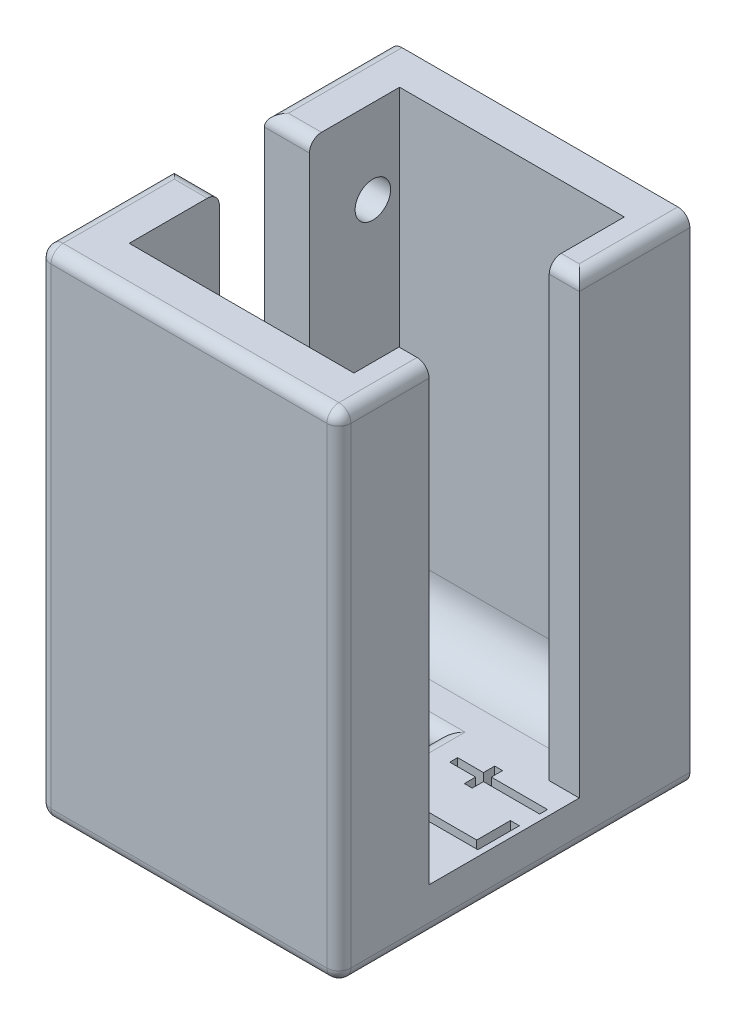
from build123d import *

# Parameters (mm, degrees)
BOSS_EXTRUDE2_DEPTH = 38.1
SKETCH1_W           = 25.35
SKETCH1_H           = 29.67
BOSS_EXTRUDE3_DEPTH = 3.81
SKETCH3_W           = 3
SKETCH3_H           = 7.62
CUT_EXTRUDE1_DEPTH  = 4.81
SKETCH4_W           = 7.62
SKETCH4_H           = 30.1
CUT_EXTRUDE2_DEPTH  = 4.81
SKETCH5_R           = 1.5
CUT_EXTRUDE3_DEPTH  = 4.81
SKETCH6_R           = 1.45
CUT_EXTRUDE4_DEPTH  = 24.844
FILLET1_R           = 4
FILLET4_R           = 2.54
FILLET2_R           = 1.016
FILLET3_R           = 1.27
FILLET5_R           = 1.016
CUT_EXTRUDE5_DEPTH  = 1.27


with BuildPart() as part:
    # Sketch2 → Boss-Extrude2 (new body)
    with BuildSketch(Plane(origin=(0, 0, 0), x_dir=(1, 0, 0), z_dir=(0, 1, 0))):
        Polygon((-9.5, -11.43), (9.5, -11.43), (9.5, -5.08), (12.04, -5.08), (12.04, -14.43), (-13.31, -14.43), (-13.31, 15.24), (12.04, 15.24), (12.04, 7.62), (9.5, 7.62), (9.5, 11.43), (-9.5, 11.43), align=None)
    extrude(amount=BOSS_EXTRUDE2_DEPTH)

    # Sketch1 → Boss-Extrude3 (add)
    with BuildSketch(Plane(origin=(0, 0, 0), x_dir=(1, 0, 0), z_dir=(0, 1, 0))):
        with Locations((-0.635, 0.405)):
            Rectangle(SKETCH1_W, SKETCH1_H)
    extrude(amount=-BOSS_EXTRUDE3_DEPTH)

    # Sketch3 → Cut-Extrude1 (cut, through all)
    with BuildSketch(Plane(origin=(0, 0, 0), x_dir=(1, 0, 0), z_dir=(0, 1, 0))):
        with Locations((-0.38, 0)):
            Rectangle(SKETCH3_W, SKETCH3_H)
    extrude(amount=-CUT_EXTRUDE1_DEPTH, mode=Mode.SUBTRACT)

    # Sketch4 → Cut-Extrude2 (cut, through all)
    with BuildSketch(Plane(origin=(-9.5, 0, 0), x_dir=(0, 0, -1), z_dir=(1, 0, 0))):
        with Locations((0, 23.05)):
            Rectangle(SKETCH4_W, SKETCH4_H)
    extrude(amount=-CUT_EXTRUDE2_DEPTH, mode=Mode.SUBTRACT)

    # Sketch5 → Cut-Extrude3 (cut, through all)
    with BuildSketch(Plane(origin=(-9.5, 0, 0), x_dir=(0, 0, -1), z_dir=(1, 0, 0))):
        with Locations((-9.1700096, 31)):
            Circle(SKETCH5_R)
        with Locations((8.2299904, 31)):
            Circle(SKETCH5_R)
    extrude(amount=-CUT_EXTRUDE3_DEPTH, mode=Mode.SUBTRACT)

    # Sketch6 → Cut-Extrude4 (cut)
    with BuildSketch(Plane.XY.offset(14.43)):
        with Locations((-11.405, 19.05)):
            Circle(SKETCH6_R)
        with Locations((-3.81, -1.905)):
            Circle(SKETCH6_R)
    extrude(amount=-CUT_EXTRUDE4_DEPTH, mode=Mode.SUBTRACT)

    # Fillet1
    fillet1_edges = [part.edges().sort_by_distance(p)[0] for p in [
        (0, 0, -11.43),
        (0, 0, 11.43),
    ]]
    fillet(fillet1_edges, radius=FILLET1_R)


with BuildPart() as body_2:
    # Mirror1: mirrored copy
    add(part.part.mirror(Plane.XY))

    # Fillet4
    fillet4_edges = [body_2.edges().sort_by_distance(p)[0] for p in [
        (-11.405, 8, -3.81),
        (-11.405, 8, 3.81),
    ]]
    fillet(fillet4_edges, radius=FILLET4_R)

    # Fillet2
    fillet2_edges = [body_2.edges().sort_by_distance(p)[0] for p in [
        (-13.31, 17.145, 15.24),
        (12.04, 17.145, 15.24),
        (12.04, -3.81, 0.405),
        (-13.31, -3.81, 0.405),
        (-0.635, -3.81, 15.24),
        (12.04, 38.1, 11.43),
        (-0.635, 38.1, 15.24),
        (-13.31, 38.1, 9.525),
        (-13.31, 38.1, -9.12),
        (-11.405, 38.1, -3.81),
        (-11.405, 38.1, 3.81),
    ]]
    fillet(fillet2_edges, radius=FILLET2_R)

    # Fillet3
    fillet3_edges = [body_2.edges().sort_by_distance(p)[0] for p in [
        (-1.88, 0, 0),
        (-0.38, 0, -3.81),
        (1.12, 0, 0),
        (-0.38, 0, 3.81),
    ]]
    fillet(fillet3_edges, radius=FILLET3_R)

    # Fillet5
    fillet5_edges = [body_2.edges().sort_by_distance(p)[0] for p in [
        (12.04, 38.1, -9.755),
        (10.77, 38.1, -5.08),
    ]]
    fillet(fillet5_edges, radius=FILLET5_R)

    # Sketch7 → Cut-Extrude5 (cut)
    with BuildSketch(Plane(origin=(0, 0, 0), x_dir=(1, 0, 0), z_dir=(0, 1, 0))):
        Polygon((4.129986879, -2.992887734), (4.129986879, -2.328037307), (10.778491153, -2.328037307), (10.778491153, 0.521321667), (11.538320213, 0.521321667), (11.538320213, -2.992887734), align=None)
        Polygon((3.940029614, 2.230937052), (3.940029614, 2.895787479), (6.124538161, 2.895787479), (6.124538161, 3.845573804), (6.789388589, 3.845573804), (6.789388589, 2.895787479), (11.538320213, 2.895787479), (11.538320213, 2.230937052), (6.789388589, 2.230937052), (6.789388589, 1.281150727), (6.124538161, 1.281150727), (6.124538161, 2.230937052), align=None)
    extrude(amount=-CUT_EXTRUDE5_DEPTH, mode=Mode.SUBTRACT)


solid = body_2.part
